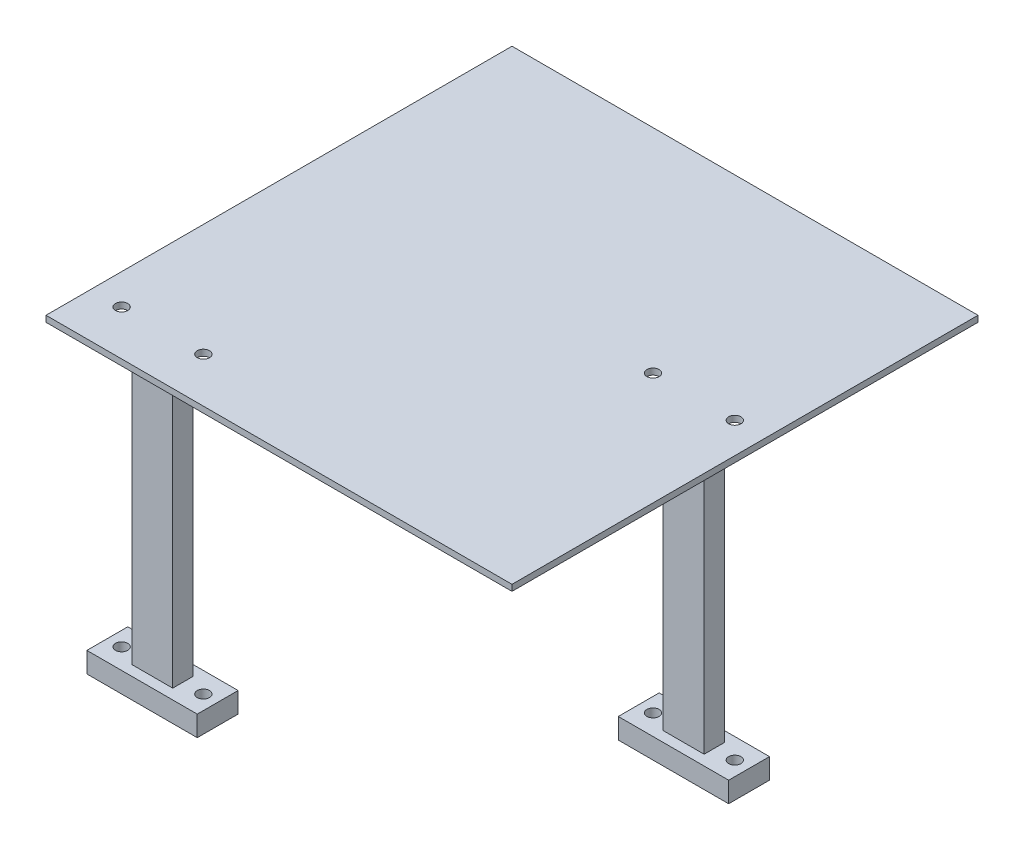
from build123d import *

# Parameters (mm, degrees)
SKETCH1_W           = 114
SKETCH1_H           = 114
SKETCH1_R           = 1.5
BOSS_EXTRUDE1_DEPTH = 1.5
SKETCH2_W           = 10
SKETCH2_H           = 5
BOSS_EXTRUDE2_DEPTH = 72
SKETCH3_W           = 27
SKETCH3_H           = 10
SKETCH3_R           = 1.5
BOSS_EXTRUDE3_DEPTH = 5


with BuildPart() as part:
    # Sketch1 → Boss-Extrude1 (new body)
    with BuildSketch(Plane(origin=(0, 0, 0), x_dir=(1, 0, 0), z_dir=(0, 1, 0))):
        Rectangle(SKETCH1_W, SKETCH1_H)
        with Locations((29.5, 5)):
            Circle(SKETCH1_R, mode=Mode.SUBTRACT)
        with Locations((49.5, 5)):
            Circle(SKETCH1_R, mode=Mode.SUBTRACT)
        with Locations((-29.5, -46)):
            Circle(SKETCH1_R, mode=Mode.SUBTRACT)
        with Locations((-49.5, -46)):
            Circle(SKETCH1_R, mode=Mode.SUBTRACT)
    extrude(amount=BOSS_EXTRUDE1_DEPTH)

    # Sketch2 → Boss-Extrude2 (add)
    with BuildSketch(Plane(origin=(0, 1.5, 0), x_dir=(1, 0, 0), z_dir=(0, 1, 0))):
        with Locations((-39.5, -46)):
            Rectangle(SKETCH2_W, SKETCH2_H)
        with Locations((39.5, 5)):
            Rectangle(SKETCH2_W, SKETCH2_H)
    extrude(amount=-BOSS_EXTRUDE2_DEPTH)

    # Sketch3 → Boss-Extrude3 (add)
    with BuildSketch(Plane(origin=(0, -70.5, 0), x_dir=(-1, 0, 0), z_dir=(0, -1, 0))):
        with Locations((39.5, -46)):
            Rectangle(SKETCH3_W, SKETCH3_H)
        with Locations((49.5, -46)):
            Circle(SKETCH3_R, mode=Mode.SUBTRACT)
        with Locations((29.5, -46)):
            Circle(SKETCH3_R, mode=Mode.SUBTRACT)
        with Locations((-39.5, 5)):
            Rectangle(SKETCH3_W, SKETCH3_H)
        with Locations((-29.5, 5)):
            Circle(SKETCH3_R, mode=Mode.SUBTRACT)
        with Locations((-49.5, 5)):
            Circle(SKETCH3_R, mode=Mode.SUBTRACT)
    extrude(amount=BOSS_EXTRUDE3_DEPTH)


solid = part.part
